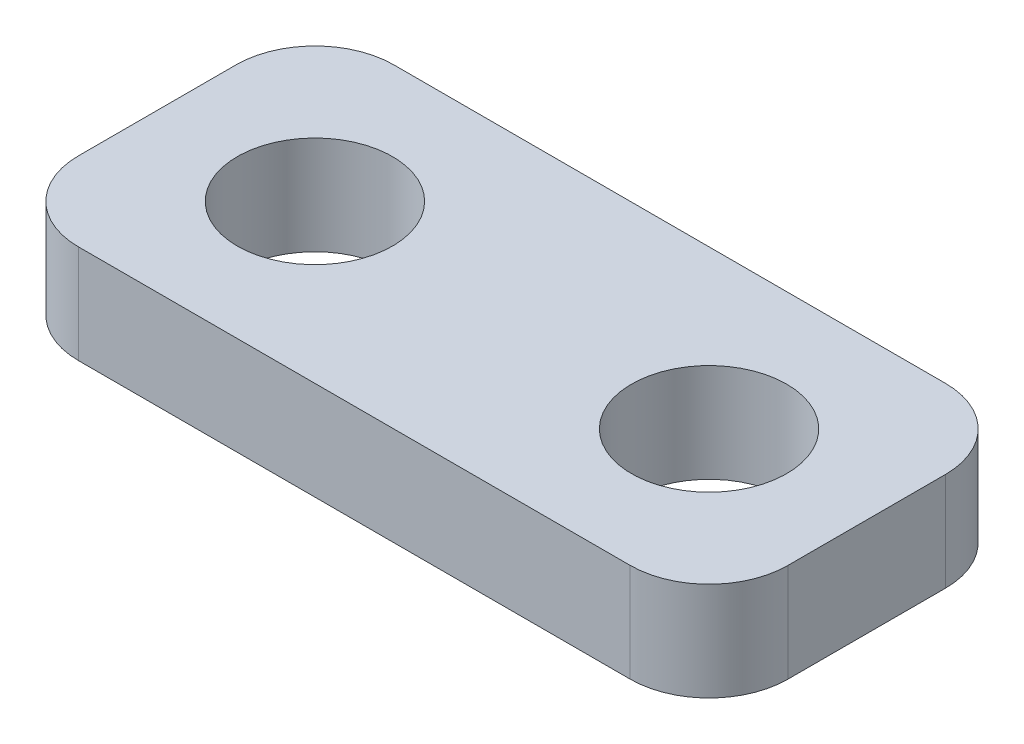
from build123d import *

# Parameters (mm, degrees)
SKETCH1_W           = 22.86
SKETCH1_H           = 10.16
BOSS_EXTRUDE1_DEPTH = 3.175
SKETCH2_R           = 2.5
CUT_EXTRUDE1_DEPTH  = 4.175
FILLET1_R           = 2.54


with BuildPart() as part:
    # Sketch1 → Boss-Extrude1 (new body)
    with BuildSketch(Plane(origin=(0, 0, 0), x_dir=(1, 0, 0), z_dir=(0, 1, 0))):
        Rectangle(SKETCH1_W, SKETCH1_H)
    extrude(amount=BOSS_EXTRUDE1_DEPTH)

    # Sketch2 → Cut-Extrude1 (cut, through all)
    with BuildSketch(Plane(origin=(0, 3.175, 0), x_dir=(1, 0, 0), z_dir=(0, 1, 0))):
        with Locations((-6.35, 0)):
            Circle(SKETCH2_R)
        with Locations((6.35, 0)):
            Circle(SKETCH2_R)
    extrude(amount=-CUT_EXTRUDE1_DEPTH, mode=Mode.SUBTRACT)

    # Fillet1
    fillet1_edges = [part.edges().sort_by_distance(p)[0] for p in [
        (11.43, 1.5875, 5.08),
        (-11.43, 1.5875, 5.08),
        (-11.43, 1.5875, -5.08),
        (11.43, 1.5875, -5.08),
    ]]
    fillet(fillet1_edges, radius=FILLET1_R)


solid = part.part
